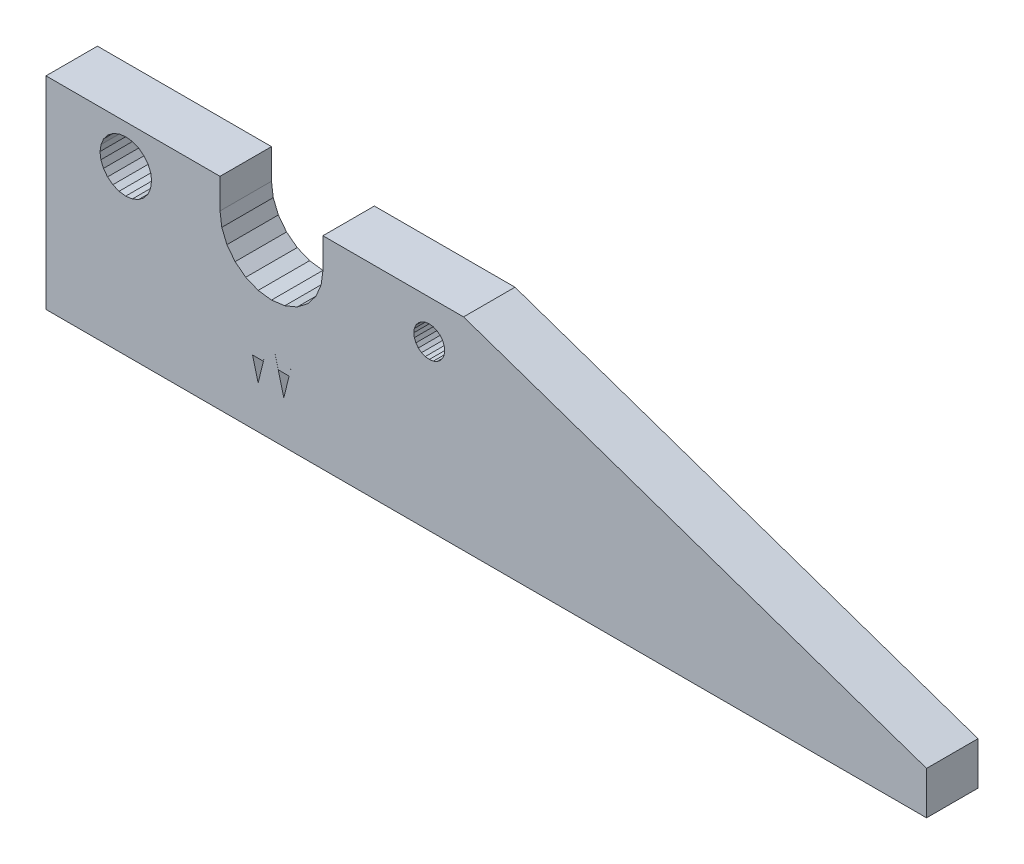
from build123d import *

# Parameters (mm, degrees)
BOSS_EXTRUDE1_DEPTH = 6


with BuildPart() as part:
    # Sketch1 → Boss-Extrude1 (new body)
    with BuildSketch(Plane.XY):
        Polygon((-380.698066711, -270.365836794), (-382.14515244, -269.766434259), (-383.387793127, -268.812922523), (-384.341304863, -267.570281836), (-384.940707398, -266.123196107), (-385.14515244, -264.570281836), (-385.14515244, -261.070281836), (-405.443422321, -261.070281836), (-405.443422321, -284.670281836), (-302.74515244, -284.670281836), (-302.74515244, -279.670281836), (-356.74515244, -261.070281836), (-373.14515244, -261.070281836), (-373.14515244, -264.570281836), (-373.349597482, -266.123196107), (-373.949000017, -267.570281836), (-374.902511753, -268.812922523), (-376.14515244, -269.766434259), (-377.59223817, -270.365836794), (-379.14515244, -270.570281836), align=None)
        Polygon((-359.84515244, -267.129127563), (-360.279278159, -267.308948324), (-360.74515244, -267.370281836), (-361.211026721, -267.308948324), (-361.64515244, -267.129127563), (-362.017944646, -266.843074042), (-362.303998167, -266.470281836), (-362.483818927, -266.036156118), (-362.54515244, -265.570281836), (-362.483818927, -265.104407555), (-362.303998167, -264.670281836), (-362.017944646, -264.29748963), (-361.64515244, -264.01143611), (-361.211026721, -263.831615349), (-360.74515244, -263.770281836), (-360.279278159, -263.831615349), (-359.84515244, -264.01143611), (-359.472360234, -264.29748963), (-359.186306713, -264.670281836), (-359.006485953, -265.104407555), (-358.94515244, -265.570281836), (-359.006485953, -266.036156118), (-359.186306713, -266.470281836), (-359.472360234, -266.843074042), align=None, mode=Mode.SUBTRACT)
        Polygon((-397.620355238, -262.972205625), (-396.896812373, -262.672504357), (-396.120355238, -262.570281836), (-395.343898102, -262.672504357), (-394.620355238, -262.972205625), (-393.999034894, -263.448961493), (-393.522279026, -264.070281836), (-393.222577759, -264.793824701), (-393.14515244, -265.381928384), (-393.14515244, -265.570281836), (-393.247374961, -266.346738972), (-393.547076229, -267.070281836), (-394.023832097, -267.69160218), (-394.64515244, -268.168358048), (-395.368695305, -268.468059315), (-396.14515244, -268.570281836), (-396.921609575, -268.468059315), (-397.64515244, -268.168358048), (-398.266472784, -267.69160218), (-398.743228652, -267.070281836), (-399.042929919, -266.346738972), (-399.14515244, -265.570281836), (-399.018132717, -264.793824701), (-398.718431449, -264.070281836), (-398.241675581, -263.448961493), align=None, mode=Mode.SUBTRACT)
        Polygon((-378.829308223, -275.402326901), (-377.705403878, -279.716351292), (-376.643951896, -275.402326901), (-377.093504107, -277.219304798), (-378.354794122, -277.219304798), align=None, mode=Mode.SUBTRACT)
        Polygon((-381.826259442, -275.402326901), (-380.702355098, -279.716351292), (-379.640903116, -275.402326901), (-380.090455326, -277.219304798), (-381.351745342, -277.219304798), align=None, mode=Mode.SUBTRACT)
    extrude(amount=BOSS_EXTRUDE1_DEPTH)


solid = part.part
